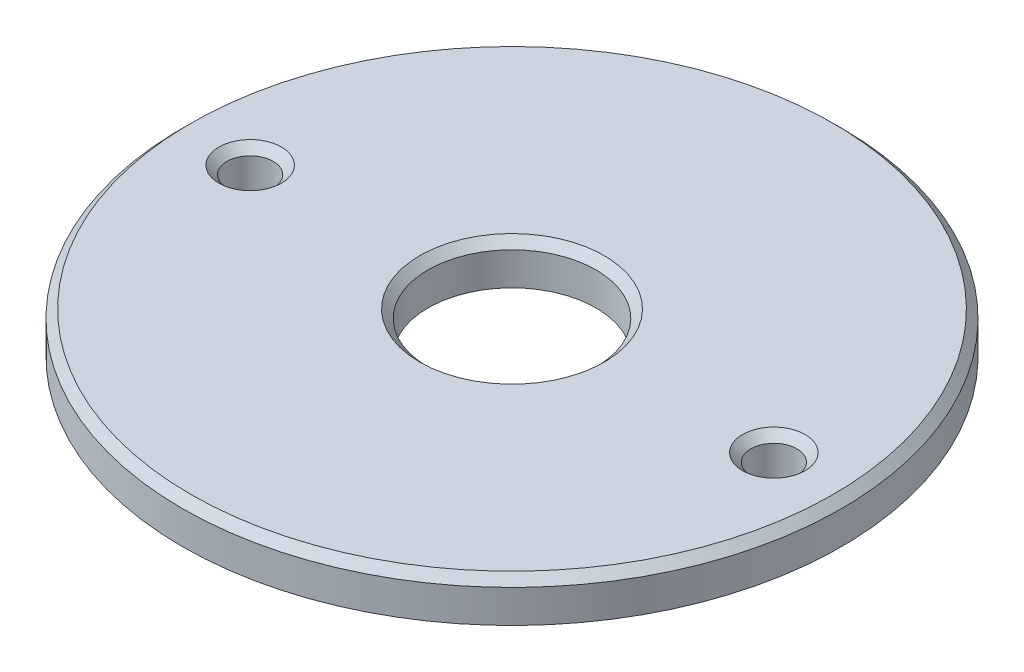
from build123d import *

# Parameters (mm, degrees)
SKETCH1_R           = 50.8
SKETCH1_R_2         = 3.556
SKETCH1_R_3         = 12.954
BOSS_EXTRUDE1_DEPTH = 6.35
CHAMFER1_SIZE       = 1.27


with BuildPart() as part:
    # Sketch1 → Boss-Extrude1 (new body)
    with BuildSketch(Plane(origin=(0, 0, 0), x_dir=(1, 0, 0), z_dir=(0, 1, 0))):
        Circle(SKETCH1_R)
        with Locations((-39.37, -0.992258715)):
            Circle(SKETCH1_R_2, mode=Mode.SUBTRACT)
        Circle(SKETCH1_R_3, mode=Mode.SUBTRACT)
        with Locations((39.37, 0.992258715)):
            Circle(SKETCH1_R_2, mode=Mode.SUBTRACT)
    extrude(amount=BOSS_EXTRUDE1_DEPTH)

    # Chamfer1
    chamfer1_edges = [part.edges().sort_by_distance(p)[0] for p in [
        (35.814, 6.35, -0.992258715),
        (-50.8, 6.35, 0),
        (-42.926, 6.35, 0.992258715),
        (-12.954, 6.35, 0),
    ]]
    chamfer(chamfer1_edges, length=CHAMFER1_SIZE)


solid = part.part
